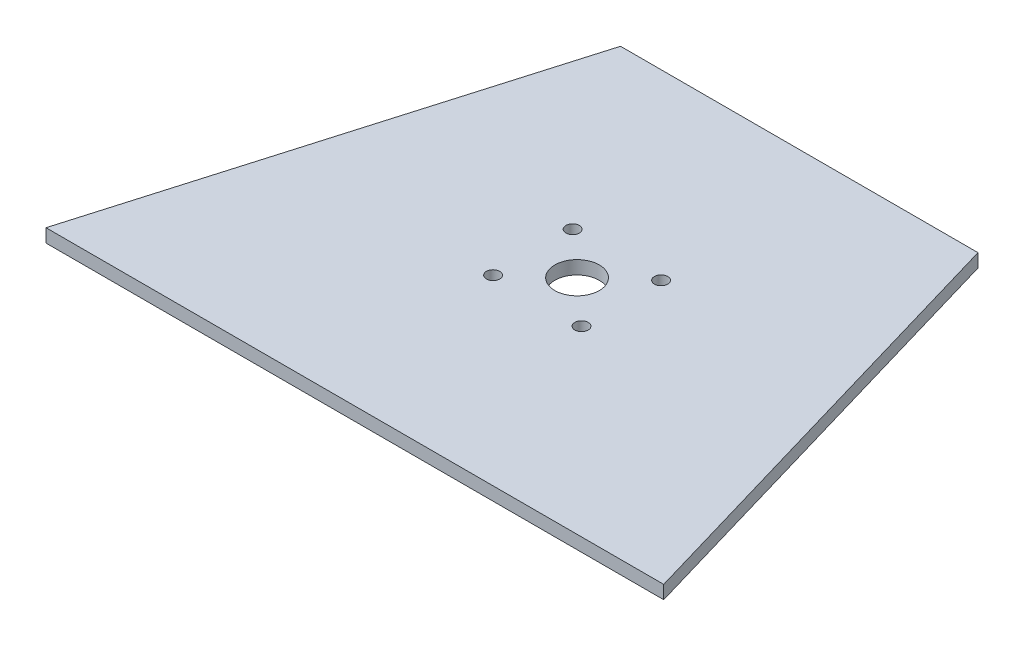
from build123d import *

# Parameters (mm, degrees)
BOSS_EXTRUDE1_DEPTH        = 3
F_10_0MM_DOWEL_HOLE1_D     = 10
F_10_0MM_DOWEL_HOLE1_DEPTH = 3
F_3_0MM_DOWEL_HOLE1_D      = 3
F_3_0MM_DOWEL_HOLE1_DEPTH  = 3


with BuildPart() as part:
    # Sketch1 → Boss-Extrude1 (new body)
    with BuildSketch(Plane(origin=(0, 0, 0), x_dir=(1, 0, 0), z_dir=(0, 1, 0))):
        Polygon((0, 0), (139, 0), (109.720058283, 100), (29.279941717, 100), align=None)
    extrude(amount=BOSS_EXTRUDE1_DEPTH)

    # Ø10.0mm Dowel Hole1
    with Locations(Plane(origin=(0, 3, 0), x_dir=(1, 0, 0), z_dir=(0, 1, 0))):
        with Locations((69.5, 50)):
            Hole(F_10_0MM_DOWEL_HOLE1_D / 2, depth=F_10_0MM_DOWEL_HOLE1_DEPTH)

    # Ø3.0mm Dowel Hole1
    with Locations(Plane(origin=(0, 3, 0), x_dir=(1, 0, 0), z_dir=(0, 1, 0))):
        with Locations((59.55, 41.05), (59.55, 58.95), (79.45, 58.95), (79.45, 41.05)):
            Hole(F_3_0MM_DOWEL_HOLE1_D / 2, depth=F_3_0MM_DOWEL_HOLE1_DEPTH)


solid = part.part
